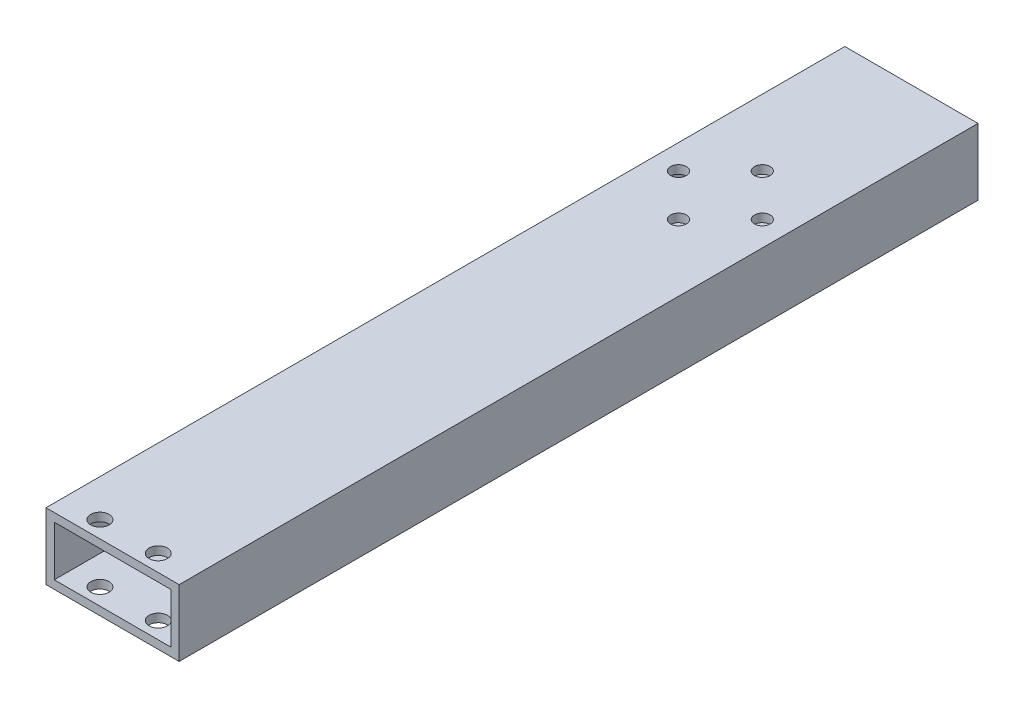
from build123d import *

# Parameters (mm, degrees)
SKETCH1_W               = 25.4
SKETCH1_H               = 12.7
BOSS_EXTRUDE1_DEPTH     = 127
SKETCH4_W               = 22.225
SKETCH4_H               = 9.525
CUT_EXTRUDE1_DEPTH      = 128
SKETCH5_R               = 1.7526
CUT_EXTRUDE2_DEPTH      = 1
CUT_EXTRUDE2_DEPTH_BACK = 13.7
SKETCH6_R               = 1.5
CUT_EXTRUDE3_DEPTH      = 1
CUT_EXTRUDE3_DEPTH_BACK = 13.7
SKETCH7_W               = 25.4
SKETCH7_H               = 12.7
SKETCH7_W_2             = 22.225
SKETCH7_H_2             = 9.525
BOSS_EXTRUDE2_DEPTH     = 25.4


with BuildPart() as part:
    # Sketch1 → Boss-Extrude1 (new body)
    with BuildSketch(Plane.XY):
        Rectangle(SKETCH1_W, SKETCH1_H)
    extrude(amount=BOSS_EXTRUDE1_DEPTH)

    # Sketch4 → Cut-Extrude1 (cut, through all)
    with BuildSketch(Plane(origin=(0, 0, 0), x_dir=(-1, 0, 0), z_dir=(0, 0, -1))):
        Rectangle(SKETCH4_W, SKETCH4_H)
    extrude(amount=-CUT_EXTRUDE1_DEPTH, mode=Mode.SUBTRACT)

    # Sketch5 → Cut-Extrude2 (cut, two sides)
    with BuildSketch(Plane(origin=(0, 6.35, 0), x_dir=(1, 0, 0), z_dir=(0, 1, 0))) as cut_extrude2_sk:
        with Locations((-5.588, -123.825)):
            Circle(SKETCH5_R)
        with Locations((5.5372, -123.825)):
            Circle(SKETCH5_R)
    extrude(amount=CUT_EXTRUDE2_DEPTH, mode=Mode.SUBTRACT)
    extrude(cut_extrude2_sk.sketch, amount=-CUT_EXTRUDE2_DEPTH_BACK, mode=Mode.SUBTRACT)

    # Sketch6 → Cut-Extrude3 (cut, two sides)
    with BuildSketch(Plane(origin=(0, -6.35, 0), x_dir=(-1, 0, 0), z_dir=(0, -1, 0))) as cut_extrude3_sk:
        with Locations((8, -11.05)):
            Circle(SKETCH6_R)
        with Locations((-8, -11.05)):
            Circle(SKETCH6_R)
        with Locations((0, -3.05)):
            Circle(SKETCH6_R)
        with Locations((0, -19.05)):
            Circle(SKETCH6_R)
    extrude(amount=CUT_EXTRUDE3_DEPTH, mode=Mode.SUBTRACT)
    extrude(cut_extrude3_sk.sketch, amount=-CUT_EXTRUDE3_DEPTH_BACK, mode=Mode.SUBTRACT)

    # Sketch7 → Boss-Extrude2 (add)
    with BuildSketch(Plane(origin=(0, 0, 0), x_dir=(-1, 0, 0), z_dir=(0, 0, -1))):
        Rectangle(SKETCH7_W, SKETCH7_H)
        Rectangle(SKETCH7_W_2, SKETCH7_H_2, mode=Mode.SUBTRACT)
    extrude(amount=BOSS_EXTRUDE2_DEPTH)


solid = part.part
